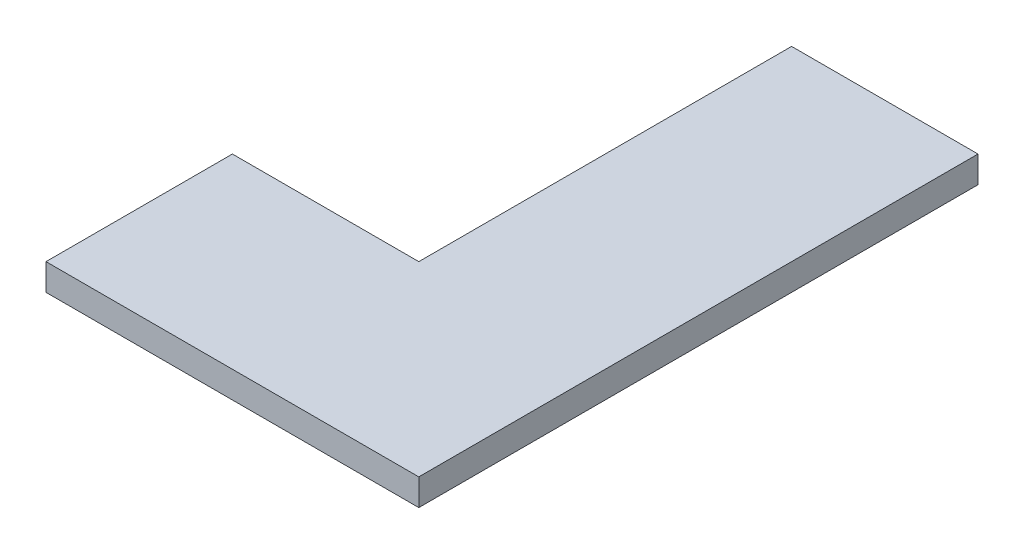
from build123d import *

# Parameters (mm, degrees)
BOSS_EXTRUDE1_DEPTH = 10


with BuildPart() as part:
    # Sketch1 → Boss-Extrude1 (new body)
    with BuildSketch(Plane(origin=(0, 0, 0), x_dir=(1, 0, 0), z_dir=(0, 1, 0))):
        Polygon((0, 105), (70, 105), (70, -105), (-70, -105), (-70, -35), (0, -35), align=None)
    extrude(amount=BOSS_EXTRUDE1_DEPTH)


solid = part.part
